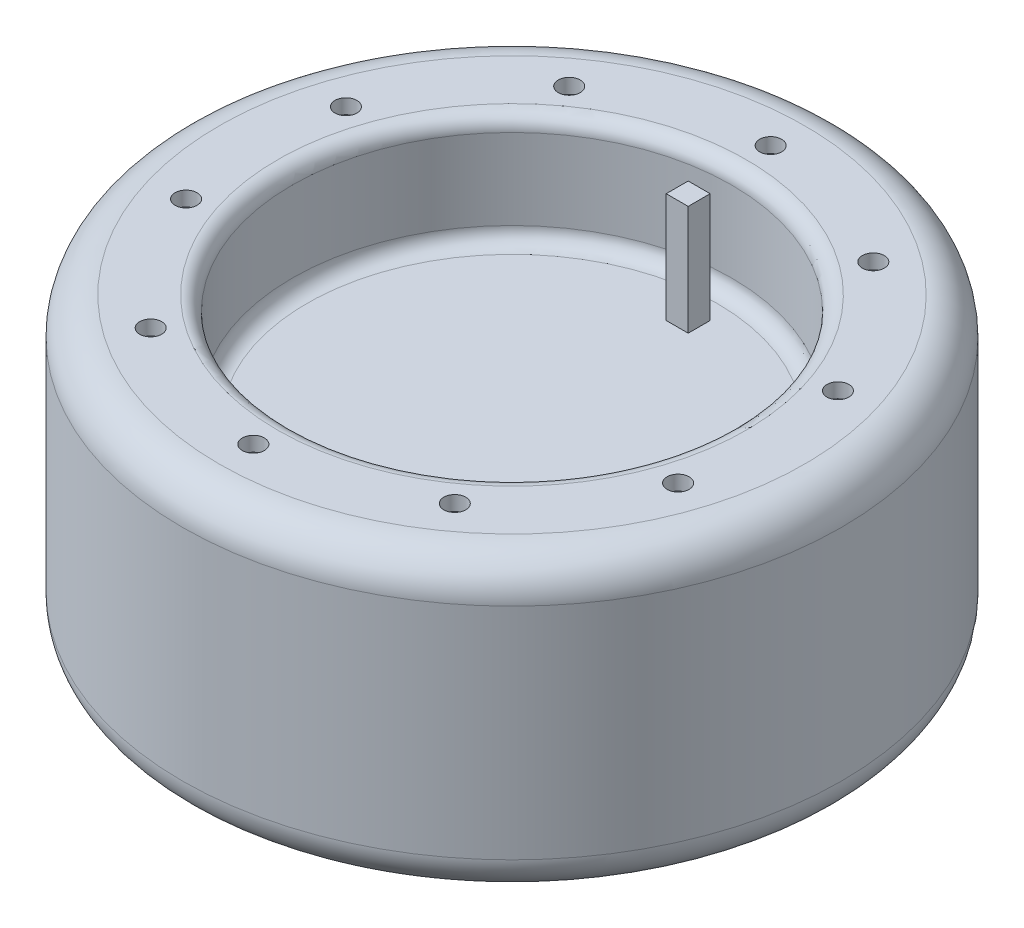
from build123d import *

# Parameters (mm, degrees)
SKETCH1_R           = 45
BOSS_EXTRUDE1_DEPTH = 40
FILLET1_R           = 5
SKETCH2_R           = 30
CUT_EXTRUDE1_DEPTH  = 15
FILLET2_R           = 2
SKETCH3_R           = 1.5
CUT_EXTRUDE2_DEPTH  = 2
SKETCH4_W           = 3
SKETCH4_H           = 3
BOSS_EXTRUDE2_DEPTH = 15


with BuildPart() as part:
    # Sketch1 → Boss-Extrude1 (new body)
    with BuildSketch(Plane(origin=(0, 0, 0), x_dir=(1, 0, 0), z_dir=(0, 1, 0))):
        Circle(SKETCH1_R)
    extrude(amount=BOSS_EXTRUDE1_DEPTH)

    # Fillet1
    fillet1_edges = [part.edges().sort_by_distance(p)[0] for p in [
        (-45, 0, 0),
        (-45, 40, 0),
    ]]
    fillet(fillet1_edges, radius=FILLET1_R)

    # Sketch2 → Cut-Extrude1 (cut)
    with BuildSketch(Plane(origin=(0, 40, 0), x_dir=(1, 0, 0), z_dir=(0, 1, 0))):
        Circle(SKETCH2_R)
    extrude(amount=-CUT_EXTRUDE1_DEPTH, mode=Mode.SUBTRACT)

    # Fillet2
    fillet2_edges = [part.edges().sort_by_distance(p)[0] for p in [
        (-30, 25, 0),
        (-30, 40, 0),
    ]]
    fillet(fillet2_edges, radius=FILLET2_R)

    # Sketch3 → Cut-Extrude2 (cut)
    with BuildSketch(Plane(origin=(0, 40, 0), x_dir=(1, 0, 0), z_dir=(0, 1, 0))):
        with Locations((0, 35.324029749)):
            Circle(SKETCH3_R)
        with Locations((20.762943738, 28.577740377)):
            Circle(SKETCH3_R)
        with Locations((33.595148675, 10.915725502)):
            Circle(SKETCH3_R)
        with Locations((33.595148675, -10.915725502)):
            Circle(SKETCH3_R)
        with Locations((20.762943738, -28.577740377)):
            Circle(SKETCH3_R)
        with Locations((0, -35.324029749)):
            Circle(SKETCH3_R)
        with Locations((-20.762943738, -28.577740377)):
            Circle(SKETCH3_R)
        with Locations((-33.595148675, -10.915725502)):
            Circle(SKETCH3_R)
        with Locations((-33.595148675, 10.915725502)):
            Circle(SKETCH3_R)
        with Locations((-20.762943738, 28.577740377)):
            Circle(SKETCH3_R)
    extrude(amount=-CUT_EXTRUDE2_DEPTH, mode=Mode.SUBTRACT)

    # Sketch4 → Boss-Extrude2 (add)
    with BuildSketch(Plane(origin=(0, 25, 0), x_dir=(1, 0, 0), z_dir=(0, 1, 0))):
        with Locations((0.059295031, 24)):
            Rectangle(SKETCH4_W, SKETCH4_H)
    extrude(amount=BOSS_EXTRUDE2_DEPTH)


solid = part.part
